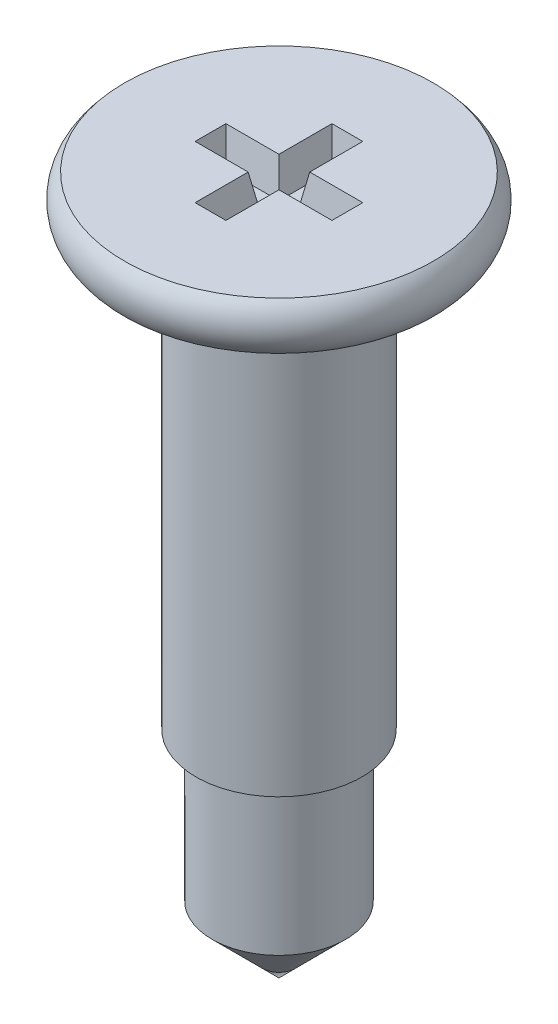
from build123d import *

# Parameters (mm, degrees)
CUT_EXTRUDE1_DEPTH = 1
CUT_EXTRUDE1_TAPER = 10


with BuildPart() as part:
    # Sketch2 → Revolve1 (revolve)
    with BuildSketch(Plane.XY):
        with BuildLine():
            Line((-2.425, 0), (-2.425, -12.7))
            Line((-2.425, -12.7), (-1.95, -12.7))
            Line((-1.95, -12.7), (-1.95, -17.05))
            Line((-1.95, -17.05), (0, -19))
            Line((0, -19), (0, 0))
            Line((0, 0), (0, 1.4))
            Line((0, 1.4), (-4.514142843, 1.4))
            ThreePointArc((-4.514142843, 1.4), (-4.8, 0.7), (-4.514142843, 0))
            Line((-4.514142843, 0), (-2.425, 0))
        make_face()
    revolve(axis=Axis((0, -19, 0), (0, -1, 0)))

    # Sketch3 → Cut-Extrude1 (cut)
    with BuildSketch(Plane(origin=(0, 1.4, 0), x_dir=(1, 0, 0), z_dir=(0, 1, 0))):
        Polygon((-0.45, 2), (-0.45, 0.45), (-2, 0.45), (-2, -0.45), (-0.45, -0.45), (-0.45, -2), (0.45, -2), (0.45, -0.45), (2, -0.45), (2, 0.45), (0.45, 0.45), (0.45, 2), align=None)
    extrude(amount=-CUT_EXTRUDE1_DEPTH, taper=CUT_EXTRUDE1_TAPER, mode=Mode.SUBTRACT)


solid = part.part
